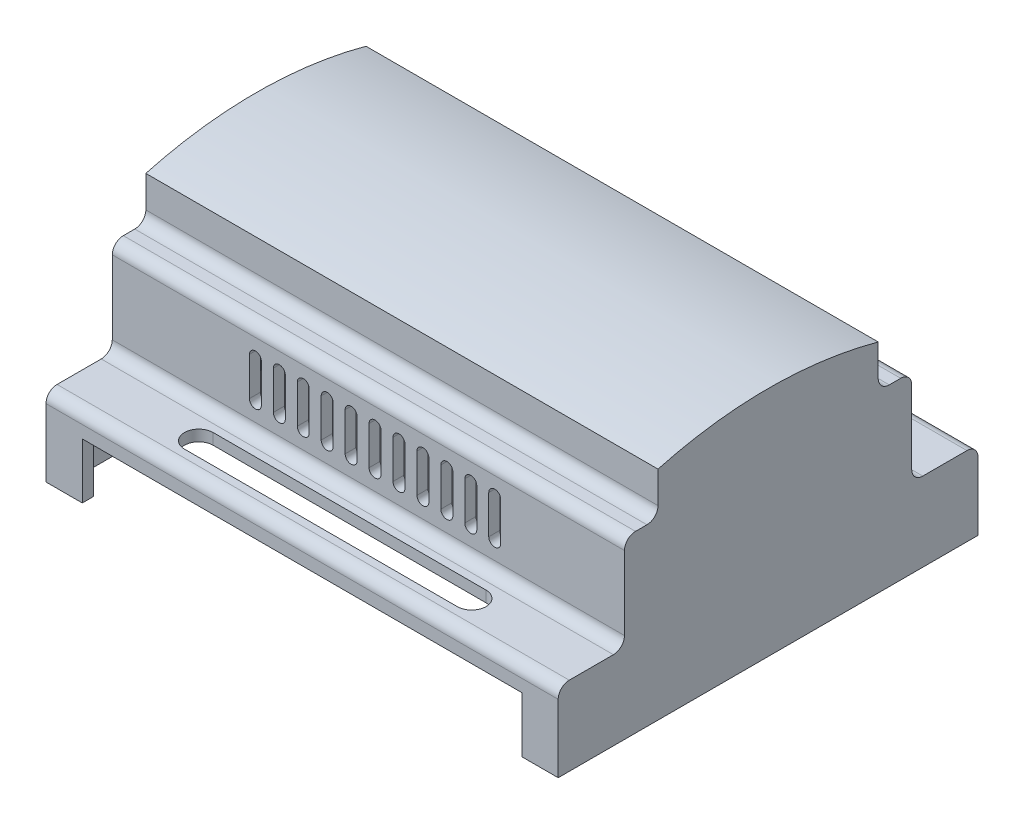
from build123d import *

# Parameters (mm, degrees)
BOSS_EXTRUDE4_DEPTH = 107
BOSS_EXTRUDE5_DEPTH = 2.31
SKETCH7_W           = 102.38
SKETCH7_H           = 83.08
CUT_EXTRUDE4_DEPTH  = 2.31
BOSS_EXTRUDE6_DEPTH = 2.31
CUT_EXTRUDE6_DEPTH  = 2.31
CUT_EXTRUDE7_DEPTH  = 70
SKETCH12_W          = 91.85
SKETCH12_H          = 11.6
CUT_EXTRUDE8_DEPTH  = 90


with BuildPart() as part:
    # Sketch1 → Boss-Extrude4 (new body)
    with BuildSketch(Plane(origin=(0, 0, 0), x_dir=(0, 0, -1), z_dir=(1, 0, 0))):
        with BuildLine():
            Line((0, 0), (87.7, 0))
            Line((87.7, 0), (87.7, 14.19))
            ThreePointArc((87.7, 14.19), (87.023416665, 15.823416665), (85.39, 16.5))
            Line((85.39, 16.5), (76.167, 16.5))
            ThreePointArc((76.167, 16.5), (74.533583335, 17.176583335), (73.857, 18.81))
            Line((73.857, 18.81), (73.857, 34.19))
            ThreePointArc((73.857, 34.19), (73.180416665, 35.823416665), (71.547, 36.5))
            Line((71.547, 36.5), (69.1628, 36.5))
            ThreePointArc((69.1628, 36.5), (67.529383335, 37.176583335), (66.8528, 38.81))
            Line((66.8528, 38.81), (66.8528, 45.417647019))
            ThreePointArc((66.8528, 45.417647019), (43.8531, 48.5), (20.8534, 45.417647019))
            Line((20.8534, 45.417647019), (20.8534, 38.81))
            ThreePointArc((20.8534, 38.81), (20.176816665, 37.176583335), (18.5434, 36.5))
            Line((18.5434, 36.5), (16.153, 36.5))
            ThreePointArc((16.153, 36.5), (14.519583335, 35.823416665), (13.843, 34.19))
            Line((13.843, 34.19), (13.843, 18.81))
            ThreePointArc((13.843, 18.81), (13.166416665, 17.176583335), (11.533, 16.5))
            Line((11.533, 16.5), (2.31, 16.5))
            ThreePointArc((2.31, 16.5), (0.676583335, 15.823416665), (0, 14.19))
            Line((0, 14.19), (0, 0))
        make_face()
        with BuildLine():
            Line((16.153, 34.19), (16.153, 18.81))
            ThreePointArc((16.153, 18.81), (14.799833329, 15.543166671), (11.533, 14.19))
            Line((11.533, 14.19), (2.31, 14.19))
            Line((2.31, 14.19), (2.31, 2.31))
            Line((2.31, 2.31), (85.39, 2.31))
            Line((85.39, 2.31), (85.39, 14.19))
            Line((85.39, 14.19), (76.167, 14.19))
            ThreePointArc((76.167, 14.19), (72.900166671, 15.543166671), (71.547, 18.81))
            Line((71.547, 18.81), (71.547, 34.19))
            Line((71.547, 34.19), (69.1628, 34.19))
            ThreePointArc((69.1628, 34.19), (65.895966671, 35.543166671), (64.5428, 38.81))
            Line((64.5428, 38.81), (64.5428, 43.634774003))
            ThreePointArc((64.5428, 43.634774003), (43.8531, 46.19), (23.1634, 43.634774003))
            Line((23.1634, 43.634774003), (23.1634, 38.81))
            ThreePointArc((23.1634, 38.81), (21.810233329, 35.543166671), (18.5434, 34.19))
            Line((18.5434, 34.19), (16.153, 34.19))
        make_face(mode=Mode.SUBTRACT)
    extrude(amount=BOSS_EXTRUDE4_DEPTH)

    # Sketch6 → Boss-Extrude5 (add)
    with BuildSketch(Plane.ZY):
        with BuildLine():
            Line((-85.39, 14.19), (-85.39, 2.31))
            Line((-85.39, 2.31), (-2.31, 2.31))
            Line((-2.31, 2.31), (-2.31, 14.19))
            Line((-2.31, 14.19), (-11.533, 14.19))
            ThreePointArc((-11.533, 14.19), (-14.799833329, 15.543166671), (-16.153, 18.81))
            Line((-16.153, 18.81), (-16.153, 34.19))
            Line((-16.153, 34.19), (-18.5434, 34.19))
            ThreePointArc((-18.5434, 34.19), (-21.810233329, 35.543166671), (-23.1634, 38.81))
            Line((-23.1634, 38.81), (-23.1634, 43.634774003))
            ThreePointArc((-23.1634, 43.634774003), (-43.8531, 46.19), (-64.5428, 43.634774003))
            Line((-64.5428, 43.634774003), (-64.5428, 38.81))
            ThreePointArc((-64.5428, 38.81), (-65.895966671, 35.543166671), (-69.1628, 34.19))
            ThreePointArc((-69.1628, 34.19), (-69.258906021, 34.189020865), (-69.355012042, 34.19))
            Line((-69.355012042, 34.19), (-71.547, 34.19))
            Line((-71.547, 34.19), (-71.547, 18.81))
            ThreePointArc((-71.547, 18.81), (-72.900166671, 15.543166671), (-76.167, 14.19))
            Line((-76.167, 14.19), (-85.39, 14.19))
        make_face()
    extrude(amount=-BOSS_EXTRUDE5_DEPTH)

    # Sketch7 → Cut-Extrude4 (cut)
    with BuildSketch(Plane.XZ):
        with Locations((53.5, -43.85)):
            Rectangle(SKETCH7_W, SKETCH7_H)
    extrude(amount=-CUT_EXTRUDE4_DEPTH, mode=Mode.SUBTRACT)

    # Sketch8 → Boss-Extrude6 (add)
    with BuildSketch(Plane(origin=(107, 0, 0), x_dir=(0, 0, -1), z_dir=(1, 0, 0))):
        with BuildLine():
            Line((2.31, 14.19), (2.31, 2.31))
            Line((2.31, 2.31), (85.39, 2.31))
            Line((85.39, 2.31), (85.39, 14.19))
            Line((85.39, 14.19), (76.167, 14.19))
            ThreePointArc((76.167, 14.19), (72.900166671, 15.543166671), (71.547, 18.81))
            Line((71.547, 18.81), (71.547, 34.19))
            Line((71.547, 34.19), (69.355012042, 34.19))
            ThreePointArc((69.355012042, 34.19), (69.258906021, 34.189020865), (69.1628, 34.19))
            ThreePointArc((69.1628, 34.19), (65.895966671, 35.543166671), (64.5428, 38.81))
            Line((64.5428, 38.81), (64.5428, 43.634774003))
            ThreePointArc((64.5428, 43.634774003), (43.8531, 46.19), (23.1634, 43.634774003))
            Line((23.1634, 43.634774003), (23.1634, 38.81))
            ThreePointArc((23.1634, 38.81), (21.810233329, 35.543166671), (18.5434, 34.19))
            Line((18.5434, 34.19), (16.153, 34.19))
            Line((16.153, 34.19), (16.153, 18.81))
            ThreePointArc((16.153, 18.81), (14.799833329, 15.543166671), (11.533, 14.19))
            Line((11.533, 14.19), (2.31, 14.19))
        make_face()
    extrude(amount=-BOSS_EXTRUDE6_DEPTH)

    # Sketch9 → Cut-Extrude6 (cut)
    with BuildSketch(Plane(origin=(0, 16.5, 0), x_dir=(1, 0, 0), z_dir=(0, 1, 0))):
        with BuildLine():
            Line((25, 83.7785), (82, 83.7785))
            ThreePointArc((82, 83.7785), (85, 80.7785), (82, 77.7785))
            Line((82, 77.7785), (25, 77.7785))
            ThreePointArc((25, 77.7785), (22, 80.7785), (25, 83.7785))
        make_face()
        with BuildLine():
            Line((25, 9.9215), (82, 9.9215))
            ThreePointArc((82, 9.9215), (85, 6.9215), (82, 3.9215))
            Line((82, 3.9215), (25, 3.9215))
            ThreePointArc((25, 3.9215), (22, 6.9215), (25, 9.9215))
        make_face()
    extrude(amount=-CUT_EXTRUDE6_DEPTH, mode=Mode.SUBTRACT)

    # Sketch11 → Cut-Extrude7 (cut)
    with BuildSketch(Plane.XY.offset(-13.843)):
        with BuildLine():
            Line((28.648320597, 30.5), (28.648320597, 22.5))
            ThreePointArc((28.648320597, 22.5), (29.898320597, 21.25), (31.148320597, 22.5))
            Line((31.148320597, 22.5), (31.148320597, 30.5))
            ThreePointArc((31.148320597, 30.5), (29.898320597, 31.75), (28.648320597, 30.5))
        make_face()
        with BuildLine():
            Line((38.648320597, 30.5), (38.648320597, 22.5))
            ThreePointArc((38.648320597, 22.5), (39.898320597, 21.25), (41.148320597, 22.5))
            Line((41.148320597, 22.5), (41.148320597, 30.5))
            ThreePointArc((41.148320597, 30.5), (39.898320597, 31.75), (38.648320597, 30.5))
        make_face()
        with BuildLine():
            Line((43.648320597, 30.5), (43.648320597, 22.5))
            ThreePointArc((43.648320597, 22.5), (44.898320597, 21.25), (46.148320597, 22.5))
            Line((46.148320597, 22.5), (46.148320597, 30.5))
            ThreePointArc((46.148320597, 30.5), (44.898320597, 31.75), (43.648320597, 30.5))
        make_face()
        with BuildLine():
            Line((48.648320597, 30.5), (48.648320597, 22.5))
            ThreePointArc((48.648320597, 22.5), (49.898320597, 21.25), (51.148320597, 22.5))
            Line((51.148320597, 22.5), (51.148320597, 30.5))
            ThreePointArc((51.148320597, 30.5), (49.898320597, 31.75), (48.648320597, 30.5))
        make_face()
        with BuildLine():
            Line((58.648320597, 30.5), (58.648320597, 22.5))
            ThreePointArc((58.648320597, 22.5), (59.898320597, 21.25), (61.148320597, 22.5))
            Line((61.148320597, 22.5), (61.148320597, 30.5))
            ThreePointArc((61.148320597, 30.5), (59.898320597, 31.75), (58.648320597, 30.5))
        make_face()
        with BuildLine():
            Line((63.648320597, 30.5), (63.648320597, 22.5))
            ThreePointArc((63.648320597, 22.5), (64.898320597, 21.25), (66.148320597, 22.5))
            Line((66.148320597, 22.5), (66.148320597, 30.5))
            ThreePointArc((66.148320597, 30.5), (64.898320597, 31.75), (63.648320597, 30.5))
        make_face()
        with BuildLine():
            Line((33.648320597, 30.5), (33.648320597, 22.5))
            ThreePointArc((33.648320597, 22.5), (34.898320597, 21.25), (36.148320597, 22.5))
            Line((36.148320597, 22.5), (36.148320597, 30.5))
            ThreePointArc((36.148320597, 30.5), (34.898320597, 31.75), (33.648320597, 30.5))
        make_face()
        with BuildLine():
            Line((53.648320597, 30.5), (53.648320597, 22.5))
            ThreePointArc((53.648320597, 22.5), (54.898320597, 21.25), (56.148320597, 22.5))
            Line((56.148320597, 22.5), (56.148320597, 30.5))
            ThreePointArc((56.148320597, 30.5), (54.898320597, 31.75), (53.648320597, 30.5))
        make_face()
        with BuildLine():
            Line((68.648320597, 30.5), (68.648320597, 22.5))
            ThreePointArc((68.648320597, 22.5), (69.898320597, 21.25), (71.148320597, 22.5))
            Line((71.148320597, 22.5), (71.148320597, 30.5))
            ThreePointArc((71.148320597, 30.5), (69.898320597, 31.75), (68.648320597, 30.5))
        make_face()
        with BuildLine():
            Line((76.148320597, 30.5), (76.148320597, 22.5))
            ThreePointArc((76.148320597, 22.5), (74.898320597, 21.25), (73.648320597, 22.5))
            Line((73.648320597, 22.5), (73.648320597, 30.5))
            ThreePointArc((73.648320597, 30.5), (74.898320597, 31.75), (76.148320597, 30.5))
        make_face()
        with BuildLine():
            Line((78.648320597, 30.5), (78.648320597, 22.5))
            ThreePointArc((78.648320597, 22.5), (79.898320597, 21.25), (81.148320597, 22.5))
            Line((81.148320597, 22.5), (81.148320597, 30.5))
            ThreePointArc((81.148320597, 30.5), (79.898320597, 31.75), (78.648320597, 30.5))
        make_face()
    extrude(amount=-CUT_EXTRUDE7_DEPTH, mode=Mode.SUBTRACT)

    # Sketch12 → Cut-Extrude8 (cut)
    with BuildSketch(Plane.XY):
        with Locations((53.505, 5.8)):
            Rectangle(SKETCH12_W, SKETCH12_H)
    extrude(amount=-CUT_EXTRUDE8_DEPTH, mode=Mode.SUBTRACT)


solid = part.part
